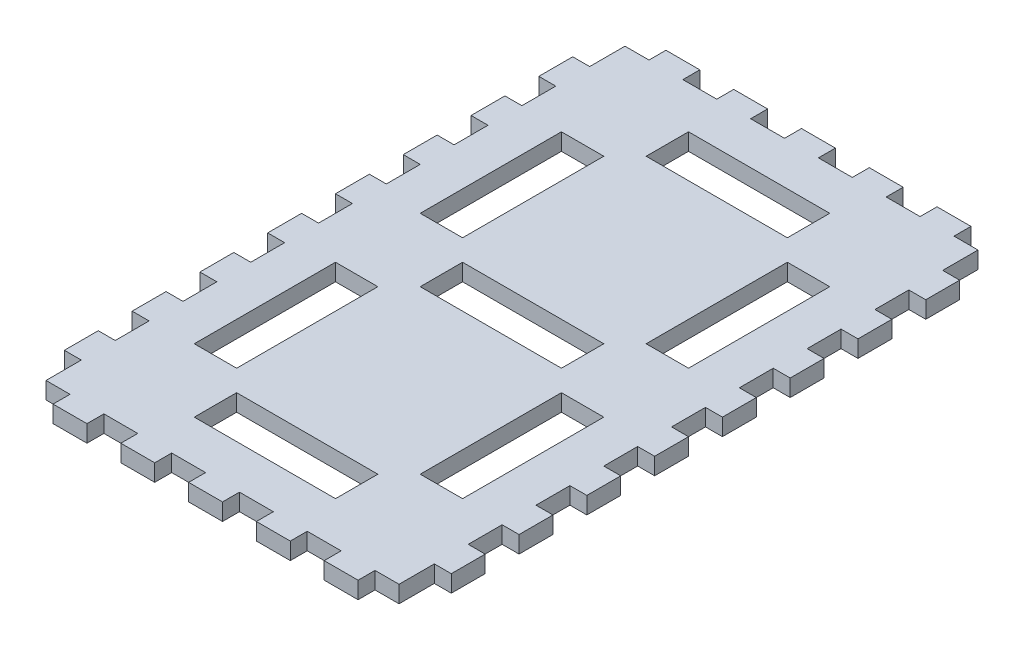
from build123d import *

# Parameters (mm, degrees)
SKETCH3_W           = 125
SKETCH3_H           = 205
BOSS_EXTRUDE1_DEPTH = 6
SKETCH4_W           = 15
SKETCH4_H           = 50
SKETCH4_W_2         = 50
SKETCH4_H_2         = 15
CUT_EXTRUDE1_DEPTH  = 6
SKETCH5_W           = 12
SKETCH5_H           = 6
SKETCH5_W_2         = 6
SKETCH5_H_2         = 12
BOSS_EXTRUDE2_DEPTH = 6


with BuildPart() as part:
    # Sketch3 → Boss-Extrude1 (new body)
    with BuildSketch(Plane(origin=(0, 0, 0), x_dir=(1, 0, 0), z_dir=(0, 1, 0))):
        Rectangle(SKETCH3_W, SKETCH3_H)
    extrude(amount=BOSS_EXTRUDE1_DEPTH)

    # Sketch4 → Cut-Extrude1 (cut)
    with BuildSketch(Plane(origin=(0, 6, 0), x_dir=(1, 0, 0), z_dir=(0, 1, 0))):
        with Locations((-40, 40)):
            Rectangle(SKETCH4_W, SKETCH4_H)
        with Locations((40, 40)):
            Rectangle(SKETCH4_W, SKETCH4_H)
        Rectangle(SKETCH4_W_2, SKETCH4_H_2)
        with Locations((-40, -40)):
            Rectangle(SKETCH4_W, SKETCH4_H)
        with Locations((40, -40)):
            Rectangle(SKETCH4_W, SKETCH4_H)
        with Locations((0, 80)):
            Rectangle(SKETCH4_W_2, SKETCH4_H_2)
        with Locations((0, -80)):
            Rectangle(SKETCH4_W_2, SKETCH4_H_2)
    extrude(amount=-CUT_EXTRUDE1_DEPTH, mode=Mode.SUBTRACT)

    # Sketch5 → Boss-Extrude2 (add)
    with BuildSketch(Plane(origin=(0, 6, 0), x_dir=(1, 0, 0), z_dir=(0, 1, 0))):
        with Locations((24, -105.5)):
            Rectangle(SKETCH5_W, SKETCH5_H)
        with Locations((0, -105.5)):
            Rectangle(SKETCH5_W, SKETCH5_H)
        with Locations((-65.5, -84)):
            Rectangle(SKETCH5_W_2, SKETCH5_H_2)
        with Locations((-65.5, -60)):
            Rectangle(SKETCH5_W_2, SKETCH5_H_2)
        with Locations((-65.5, -12)):
            Rectangle(SKETCH5_W_2, SKETCH5_H_2)
        with Locations((65.5, -84)):
            Rectangle(SKETCH5_W_2, SKETCH5_H_2)
        with Locations((65.5, -36)):
            Rectangle(SKETCH5_W_2, SKETCH5_H_2)
        with Locations((65.5, -12)):
            Rectangle(SKETCH5_W_2, SKETCH5_H_2)
        with Locations((65.5, 12)):
            Rectangle(SKETCH5_W_2, SKETCH5_H_2)
        with Locations((65.5, 36)):
            Rectangle(SKETCH5_W_2, SKETCH5_H_2)
        with Locations((65.5, 84)):
            Rectangle(SKETCH5_W_2, SKETCH5_H_2)
        with Locations((24, 105.5)):
            Rectangle(SKETCH5_W, SKETCH5_H)
        with Locations((0, 105.5)):
            Rectangle(SKETCH5_W, SKETCH5_H)
        with Locations((-24, 105.5)):
            Rectangle(SKETCH5_W, SKETCH5_H)
        with Locations((-48, 105.5)):
            Rectangle(SKETCH5_W, SKETCH5_H)
        with Locations((-65.5, 36)):
            Rectangle(SKETCH5_W_2, SKETCH5_H_2)
        with Locations((-65.5, 12)):
            Rectangle(SKETCH5_W_2, SKETCH5_H_2)
        with Locations((48, -105.5)):
            Rectangle(SKETCH5_W, SKETCH5_H)
        with Locations((-24, -105.5)):
            Rectangle(SKETCH5_W, SKETCH5_H)
        with Locations((-48, -105.5)):
            Rectangle(SKETCH5_W, SKETCH5_H)
        with Locations((-65.5, -36)):
            Rectangle(SKETCH5_W_2, SKETCH5_H_2)
        with Locations((65.5, -60)):
            Rectangle(SKETCH5_W_2, SKETCH5_H_2)
        with Locations((65.5, 60)):
            Rectangle(SKETCH5_W_2, SKETCH5_H_2)
        with Locations((48, 105.5)):
            Rectangle(SKETCH5_W, SKETCH5_H)
        with Locations((-65.5, 84)):
            Rectangle(SKETCH5_W_2, SKETCH5_H_2)
        with Locations((-65.5, 60)):
            Rectangle(SKETCH5_W_2, SKETCH5_H_2)
    extrude(amount=-BOSS_EXTRUDE2_DEPTH)


solid = part.part
